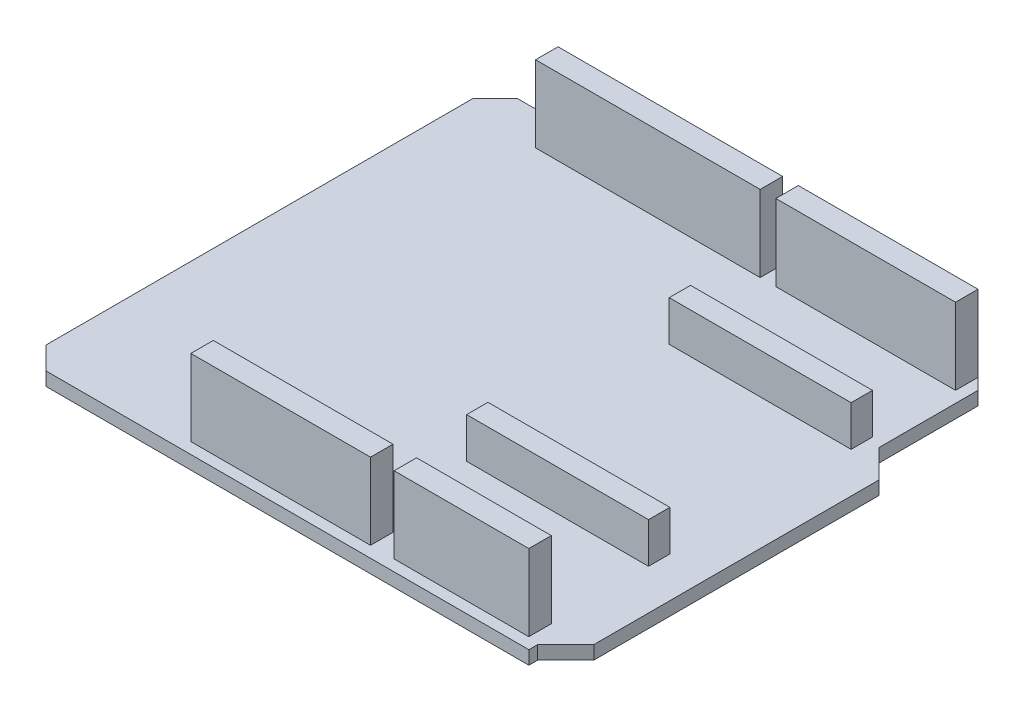
from build123d import *

# Parameters (mm, degrees)
BOSS_EXTRUDE1_DEPTH            = 0.762
F_1_3_1_3_DIAMETER_HOLE1_D     = 1.3
F_1_3_1_3_DIAMETER_HOLE1_DEPTH = 1.524
SKETCH6_W                      = 25.4
SKETCH6_H                      = 2.54
BOSS_EXTRUDE2_DEPTH            = 8.636
SKETCH6_W_2                    = 20.32
BOSS_EXTRUDE2_2_DEPTH          = 8.636
BOSS_EXTRUDE2_3_DEPTH          = 8.636
SKETCH6_W_3                    = 15.24
BOSS_EXTRUDE2_4_DEPTH          = 8.636
SKETCH7_W                      = 20.574
SKETCH7_H                      = 2.413
BOSS_EXTRUDE3_DEPTH            = 4.572
BOSS_EXTRUDE3_2_DEPTH          = 4.572


with BuildPart() as part:
    # Sketch1 → Boss-Extrude1 (new body, symmetric)
    with BuildSketch(Plane(origin=(0, 0, 0), x_dir=(1, 0, 0), z_dir=(0, 1, 0))):
        Polygon((57.15, 39.608), (60.325, 36.433), (60.325, 4.175), (57.15, 1), (57.15, 0), (2.54, 0), (0, 2.54), (0, 50.8), (2.54, 53.34), (54.61, 53.34), (57.15, 50.8), align=None)
    extrude(amount=BOSS_EXTRUDE1_DEPTH, both=True)

    # Ø1.3 (1.3) Diameter Hole1
    with Locations(Plane(origin=(0, 0.762, 0), x_dir=(1, 0, 0), z_dir=(0, 1, 0))):
        with Locations((18.923, 2.54), (9.652, 50.8), (21.463, 2.54), (24.003, 2.54), (26.543, 2.54), (29.083, 2.54), (31.623, 2.54), (34.163, 2.54), (36.703, 2.54), (12.192, 50.8), (14.732, 50.8), (17.272, 50.8), (19.812, 50.8), (22.352, 50.8), (24.892, 50.8), (27.432, 50.8), (29.972, 50.8), (32.512, 50.8), (41.91, 2.54), (36.83, 50.8), (44.45, 2.54), (46.99, 2.54), (49.53, 2.54), (52.07, 2.54), (54.61, 2.54), (39.37, 50.8), (41.91, 50.8), (44.45, 50.8), (46.99, 50.8), (49.53, 50.8), (52.07, 50.8), (54.61, 50.8), (91.567, 2.54), (89.027, 2.54), (86.487, 2.54), (83.947, 2.54), (81.407, 2.54), (78.867, 2.54), (76.327, 2.54)):
            Hole(F_1_3_1_3_DIAMETER_HOLE1_D / 2, depth=F_1_3_1_3_DIAMETER_HOLE1_DEPTH)


with BuildPart() as body_2:
    # Sketch6 → Boss-Extrude2 (new body)
    with BuildSketch(Plane(origin=(0, 0.762, 0), x_dir=(1, 0, 0), z_dir=(0, 1, 0))):
        with Locations((21.082, 50.8)):
            Rectangle(SKETCH6_W, SKETCH6_H)
    extrude(amount=BOSS_EXTRUDE2_DEPTH)


with BuildPart() as body_3:
    # Sketch6 → Boss-Extrude2 2 (new body)
    with BuildSketch(Plane(origin=(0, 0.762, 0), x_dir=(1, 0, 0), z_dir=(0, 1, 0))):
        with Locations((45.72, 50.8)):
            Rectangle(SKETCH6_W_2, SKETCH6_H)
    extrude(amount=BOSS_EXTRUDE2_2_DEPTH)


with BuildPart() as body_4:
    # Sketch6 → Boss-Extrude2 3 (new body)
    with BuildSketch(Plane(origin=(0, 0.762, 0), x_dir=(1, 0, 0), z_dir=(0, 1, 0))):
        with Locations((27.813, 2.54)):
            Rectangle(SKETCH6_W_2, SKETCH6_H)
    extrude(amount=BOSS_EXTRUDE2_3_DEPTH)


with BuildPart() as body_5:
    # Sketch6 → Boss-Extrude2 4 (new body)
    with BuildSketch(Plane(origin=(0, 0.762, 0), x_dir=(1, 0, 0), z_dir=(0, 1, 0))):
        with Locations((48.26, 2.54)):
            Rectangle(SKETCH6_W_3, SKETCH6_H)
    extrude(amount=BOSS_EXTRUDE2_4_DEPTH)


with BuildPart() as body_6:
    # Sketch7 → Boss-Extrude3 (new body)
    with BuildSketch(Plane(origin=(0, 0.762, 0), x_dir=(1, 0, 0), z_dir=(0, 1, 0))):
        with Locations((45.466, 39.0525)):
            Rectangle(SKETCH7_W, SKETCH7_H)
    extrude(amount=BOSS_EXTRUDE3_DEPTH)


with BuildPart() as body_7:
    # Sketch7 → Boss-Extrude3 2 (new body)
    with BuildSketch(Plane(origin=(0, 0.762, 0), x_dir=(1, 0, 0), z_dir=(0, 1, 0))):
        with Locations((45.466, 16.1395)):
            Rectangle(SKETCH7_W, SKETCH7_H)
    extrude(amount=BOSS_EXTRUDE3_2_DEPTH)


solid = Compound([part.part, body_2.part, body_3.part, body_4.part, body_5.part, body_6.part, body_7.part])
